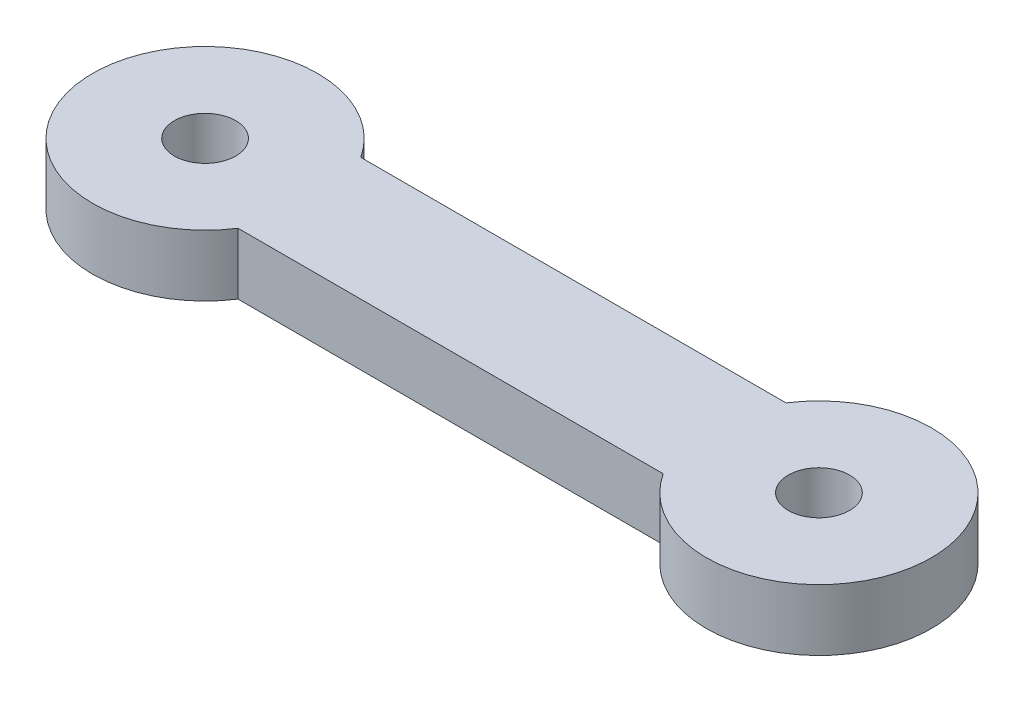
from build123d import *

# Parameters (mm, degrees)
SKETCH1_R           = 1.5
BOSS_EXTRUDE1_DEPTH = 3


with BuildPart() as part:
    # Sketch1 → Boss-Extrude1 (new body)
    with BuildSketch(Plane(origin=(0, 0, 0), x_dir=(1, 0, 0), z_dir=(0, 1, 0))):
        with BuildLine():
            ThreePointArc((4.609772229, 3), (-5.5, 0), (4.609772229, -3))
            Line((4.609772229, -3), (25.390227771, -3))
            ThreePointArc((25.390227771, -3), (35.5, 0), (25.390227771, 3))
            Line((25.390227771, 3), (4.609772229, 3))
        make_face()
        Circle(SKETCH1_R, mode=Mode.SUBTRACT)
        with Locations((30, 0)):
            Circle(SKETCH1_R, mode=Mode.SUBTRACT)
    extrude(amount=BOSS_EXTRUDE1_DEPTH)


solid = part.part
